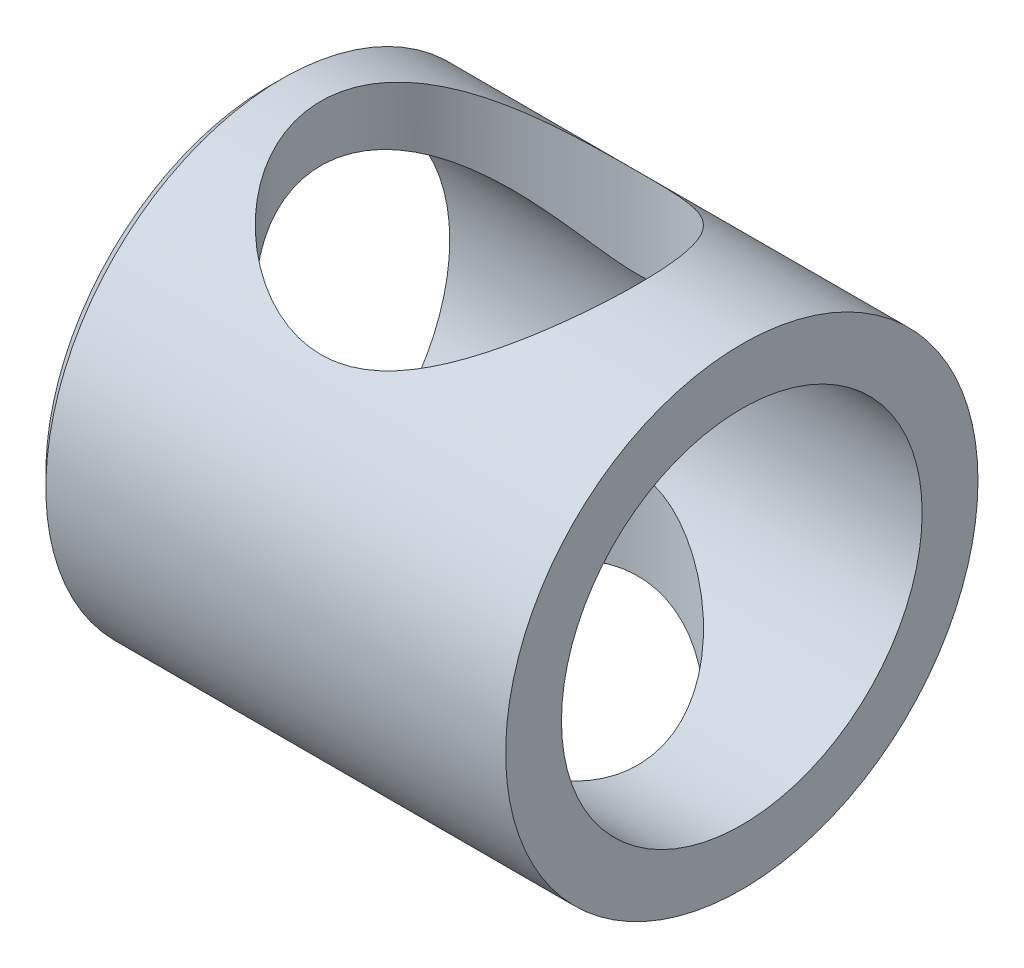
from build123d import *

# Parameters (mm, degrees)
SKETCH1_R           = 14.2875
SKETCH1_R_2         = 10.9093
BOSS_EXTRUDE1_DEPTH = 28.575
SKETCH2_R           = 9.5885
CUT_EXTRUDE1_DEPTH  = 19.05
CHAMFER1_SIZE       = 0.762


with BuildPart() as part:
    # Sketch1 → Boss-Extrude1 (new body)
    with BuildSketch(Plane(origin=(0, 0, 0), x_dir=(0, 0, -1), z_dir=(1, 0, 0))):
        Circle(SKETCH1_R)
        Circle(SKETCH1_R_2, mode=Mode.SUBTRACT)
    extrude(amount=BOSS_EXTRUDE1_DEPTH)

    # Sketch2 → Cut-Extrude1 (cut, symmetric)
    with BuildSketch(Plane(origin=(0, 0, 0), x_dir=(1, 0, 0), z_dir=(0, 1, 0))):
        with Locations((12.7, 0)):
            Circle(SKETCH2_R)
    extrude(amount=CUT_EXTRUDE1_DEPTH, both=True, mode=Mode.SUBTRACT)

    # Chamfer1
    chamfer1_edges = [part.edges().sort_by_distance(p)[0] for p in [
        (0, 0, 14.2875),
    ]]
    chamfer(chamfer1_edges, length=CHAMFER1_SIZE)


solid = part.part
